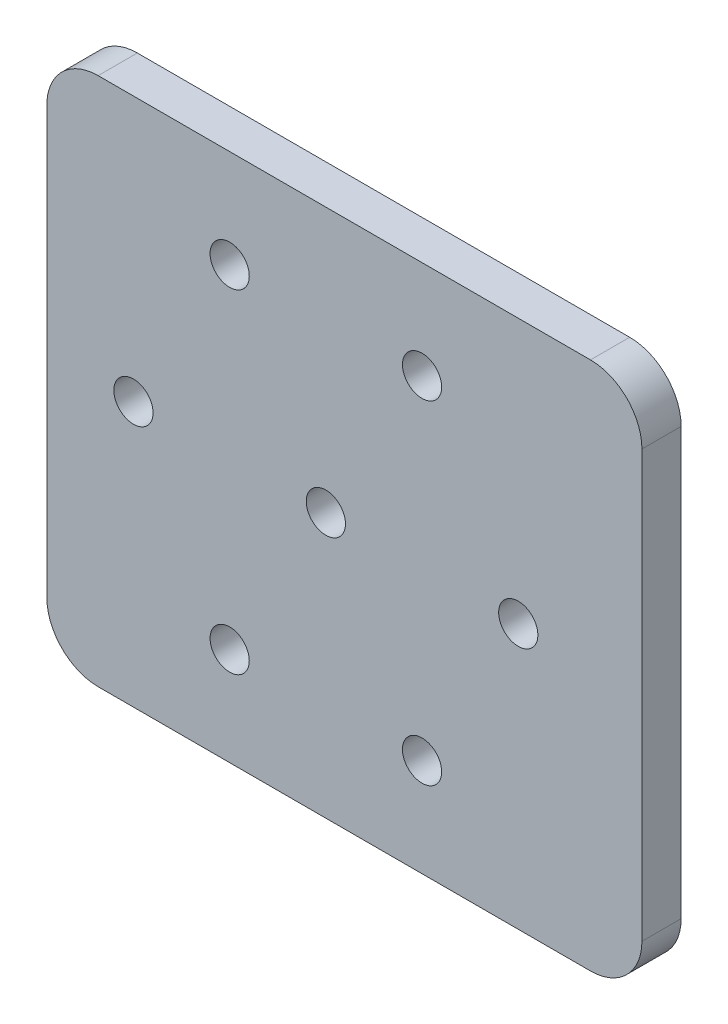
from build123d import *

# Parameters (mm, degrees)
BOSS_EXTRUDE1_DEPTH    = 25.4
CUT_EXTRUDE1_DEPTH     = 25.4
F_1_1_DIAMETER_HOLE1_D = 25.4


with BuildPart() as part:
    # Sketch1 → Boss-Extrude1 (new body)
    with BuildSketch(Plane.XY):
        with BuildLine():
            Line((-196.85, -171.45), (196.85, -171.45))
            ThreePointArc((196.85, -171.45), (220.423172318, -161.685672318), (230.1875, -138.1125))
            Line((230.1875, -138.1125), (230.1875, 138.1125))
            ThreePointArc((230.1875, 138.1125), (220.423172318, 161.685672318), (196.85, 171.45))
            Line((196.85, 171.45), (-196.85, 171.45))
            ThreePointArc((-196.85, 171.45), (-220.423172318, 161.685672318), (-230.1875, 138.1125))
            Line((-230.1875, 138.1125), (-230.1875, -138.1125))
            ThreePointArc((-230.1875, -138.1125), (-220.423172318, -161.685672318), (-196.85, -171.45))
        make_face()
    extrude(amount=BOSS_EXTRUDE1_DEPTH)

    # Sketch2 → Cut-Extrude1 (cut)
    with BuildSketch(Plane.XY.offset(25.4)):
        with BuildLine():
            Line((-230.1875, 138.1125), (-230.1875, -138.1125))
            ThreePointArc((-230.1875, -138.1125), (-220.423172318, -161.685672318), (-196.85, -171.45))
            Line((-196.85, -171.45), (-122.025168103, -171.45))
            ThreePointArc((-122.025168103, -171.45), (-145.59834042, -161.685672318), (-155.362668103, -138.1125))
            Line((-155.362668103, -138.1125), (-155.362668103, 139.975839194))
            ThreePointArc((-155.362668103, 139.975839194), (-145.020467472, 162.332230308), (-122.137381725, 171.45))
            Line((-122.137381725, 171.45), (-155.460095347, 171.45))
            Line((-155.460095347, 171.45), (-196.85, 171.45))
            ThreePointArc((-196.85, 171.45), (-220.423172318, 161.685672318), (-230.1875, 138.1125))
        make_face()
    extrude(amount=-CUT_EXTRUDE1_DEPTH, mode=Mode.SUBTRACT)

    # 1 (1) Diameter Hole1 (through all)
    with Locations(Plane.XY.offset(25.4)):
        with Locations((25.4, 0), (-36.924961559, 107.95), (87.724961559, 107.95), (150.049923118, 0), (87.724961559, -107.95), (-36.924961559, -107.95), (-99.249923118, 0)):
            Hole(F_1_1_DIAMETER_HOLE1_D / 2)


solid = part.part
